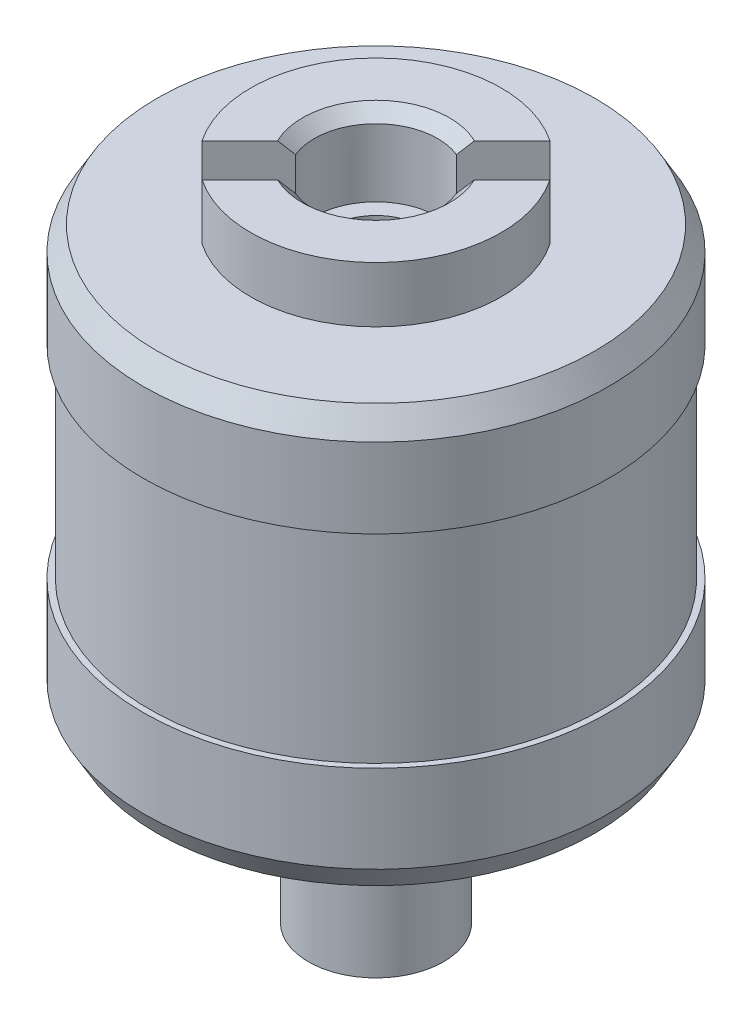
from build123d import *

# Parameters (mm, degrees)
F_2_56_TAPPED_HOLE1_D           = 1.778
F_2_56_TAPPED_HOLE1_DEPTH       = 3.73
F_2_56_TAPPED_HOLE1_TIP         = 0.53416509
F_4_40_TAPPED_HOLE1_D           = 2.2606
F_4_40_TAPPED_HOLE1_DEPTH       = 7.6
F_4_40_TAPPED_HOLE1_TIP         = 0.679152758
SKETCH_5_R                      = 1.55
CUT_EXTRUDE_1_DEPTH             = 2
CHAMFER_1_SIZE                  = 0.3
CUT_EXTRUDE_2_REACH             = 20.906
SKETCH_6_W                      = 1.2
SKETCH_6_H                      = 1.4
CUT_EXTRUDE_2_DIRECTION_2_REACH = 20.906


with BuildPart() as part:
    # Эскиз1 → Повернуть1 (revolve)
    with BuildSketch(Plane(origin=(0, 0, 0), x_dir=(0, 0, -1), z_dir=(1, 0, 0))):
        Polygon((0, 0), (0, 17), (-3.15, 17), (-3.15, 15.6), (-5.503589838, 15.6), (-5.85, 15), (-5.85, 13), (-5.7, 13), (-5.7, 7.9), (-5.85, 7.9), (-5.85, 5.7), (-5.503589838, 5.1), (-3.65, 5.1), (-3.65, 4.6), (-3.15, 4.6), (-3.15, 4), (-1.25, 4), (-1.25, 3.015093392), (-1.7, 2.7), (-1.7, 0.4), (-1.128740797, 0), align=None)
    revolve(axis=Axis((0, 0, 0), (0, 1, 0)))

    # 2-56 Tapped Hole1
    with Locations(Plane(origin=(0, 10.6, -5.7), x_dir=(-1, 0, 0), z_dir=(0, 0, -1))):
        with Locations((0, 0)):
            Hole(F_2_56_TAPPED_HOLE1_D / 2, depth=F_2_56_TAPPED_HOLE1_DEPTH)
            with Locations((0, 0, -(F_2_56_TAPPED_HOLE1_DEPTH + F_2_56_TAPPED_HOLE1_TIP / 2))):  # 118° drill point
                Cone(0, F_2_56_TAPPED_HOLE1_D / 2, F_2_56_TAPPED_HOLE1_TIP, mode=Mode.SUBTRACT)

    # 4-40 Tapped Hole1
    with Locations(Plane(origin=(0, 17, 0), x_dir=(-1, 0, 0), z_dir=(0, 1, 0))):
        with Locations((0, 0)):
            Hole(F_4_40_TAPPED_HOLE1_D / 2, depth=F_4_40_TAPPED_HOLE1_DEPTH)
            with Locations((0, 0, -(F_4_40_TAPPED_HOLE1_DEPTH + F_4_40_TAPPED_HOLE1_TIP / 2))):  # 118° drill point
                Cone(0, F_4_40_TAPPED_HOLE1_D / 2, F_4_40_TAPPED_HOLE1_TIP, mode=Mode.SUBTRACT)

    # Эскиз5 → Вырез-Вытянуть1 (cut)
    with BuildSketch(Plane(origin=(0, 17, 0), x_dir=(-1, 0, 0), z_dir=(0, 1, 0))):
        Circle(SKETCH_5_R)
    extrude(amount=-CUT_EXTRUDE_1_DEPTH, mode=Mode.SUBTRACT)

    # Фаска1
    chamfer_1_edges = [part.edges().sort_by_distance(p)[0] for p in [
        (1.55, 17, 0),
    ]]
    chamfer(chamfer_1_edges, length=CHAMFER_1_SIZE)

    # Эскиз6 → Вырез-Вытянуть2 (cut, up to next)
    with BuildSketch(Plane(origin=(0, 0, 0), x_dir=(0.7071067811865462, 0, 0.7071067811865488), z_dir=(-0.7071067811865488, 0, 0.7071067811865462)), mode=Mode.PRIVATE) as cut_extrude_2_sk1:
        with Locations((0, 16.3)):
            Rectangle(SKETCH_6_W, SKETCH_6_H)
    cut_extrude_2_tool1 = extrude(cut_extrude_2_sk1.sketch, amount=-CUT_EXTRUDE_2_REACH, mode=Mode.PRIVATE) & part.part
    add(cut_extrude_2_tool1.solids().sort_by_distance((0, 16.3, 0))[0], mode=Mode.SUBTRACT)

    # Эскиз6 → Вырез-Вытянуть2 direction 2 (cut, up to next)
    with BuildSketch(Plane(origin=(0, 0, 0), x_dir=(0.7071067811865462, 0, 0.7071067811865488), z_dir=(-0.7071067811865488, 0, 0.7071067811865462)), mode=Mode.PRIVATE) as cut_extrude_2_direction_2_sk1:
        with Locations((0, 16.3)):
            Rectangle(SKETCH_6_W, SKETCH_6_H)
    cut_extrude_2_direction_2_tool1 = extrude(cut_extrude_2_direction_2_sk1.sketch, amount=CUT_EXTRUDE_2_DIRECTION_2_REACH, mode=Mode.PRIVATE) & part.part
    add(cut_extrude_2_direction_2_tool1.solids().sort_by_distance((0, 16.3, 0))[0], mode=Mode.SUBTRACT)


solid = part.part
